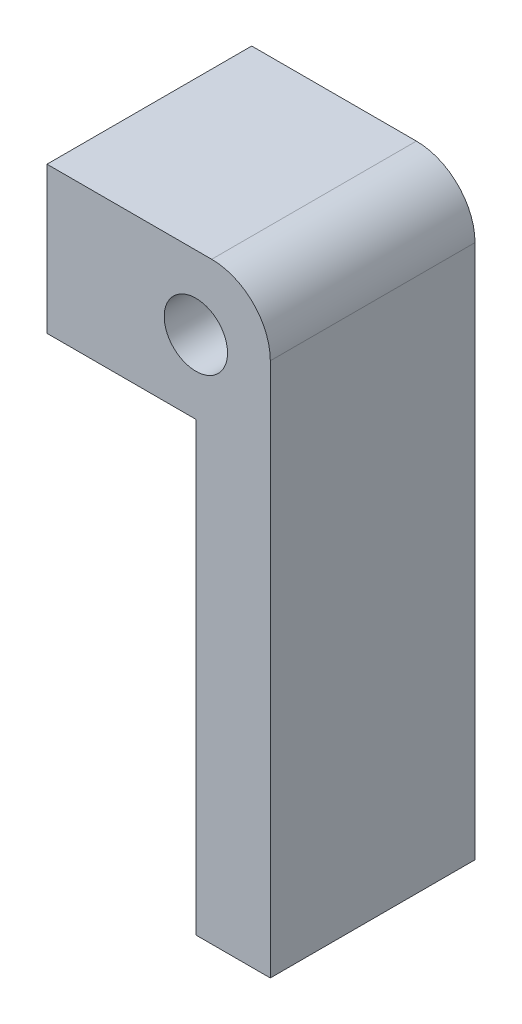
from build123d import *

# Parameters (mm, degrees)
SKETCH1_R           = 5.4
BOSS_EXTRUDE1_DEPTH = 34.925
FILLET1_R           = 10


with BuildPart() as part:
    # Sketch1 → Boss-Extrude1 (new body)
    with BuildSketch(Plane.XY):
        Polygon((0, 0), (25.4, 0), (25.4, -76.2), (38.1, -76.2), (38.1, 25), (0, 25), align=None)
        with Locations((25.4, 12.5)):
            Circle(SKETCH1_R, mode=Mode.SUBTRACT)
    extrude(amount=BOSS_EXTRUDE1_DEPTH)

    # Fillet1
    fillet1_edges = [part.edges().sort_by_distance(p)[0] for p in [
        (38.1, 25, 17.4625),
    ]]
    fillet(fillet1_edges, radius=FILLET1_R)


solid = part.part
